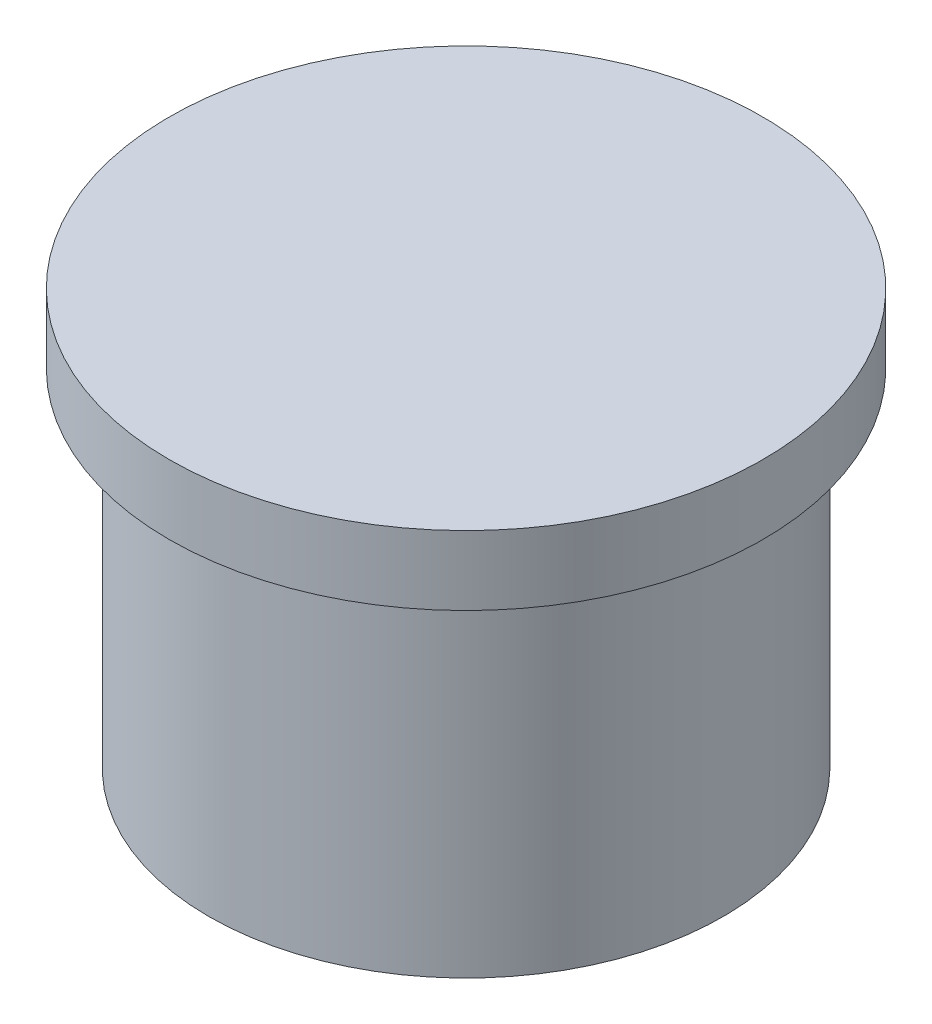
from build123d import *

# Parameters (mm, degrees)
SCHIZZO1_R                   = 26
ESTRUSIONE_ESTRUSIONE1_DEPTH = 35
SCHIZZO2_R                   = 30
ESTRUSIONE_ESTRUSIONE2_DEPTH = 7


with BuildPart() as part:
    # Schizzo1 → Estrusione-Estrusione1 (new body)
    with BuildSketch(Plane(origin=(0, 0, 0), x_dir=(1, 0, 0), z_dir=(0, 1, 0))):
        Circle(SCHIZZO1_R)
    extrude(amount=ESTRUSIONE_ESTRUSIONE1_DEPTH)

    # Schizzo2 → Estrusione-Estrusione2 (add)
    with BuildSketch(Plane(origin=(0, 35, 0), x_dir=(1, 0, 0), z_dir=(0, 1, 0))):
        Circle(SCHIZZO2_R)
    extrude(amount=ESTRUSIONE_ESTRUSIONE2_DEPTH)


solid = part.part
